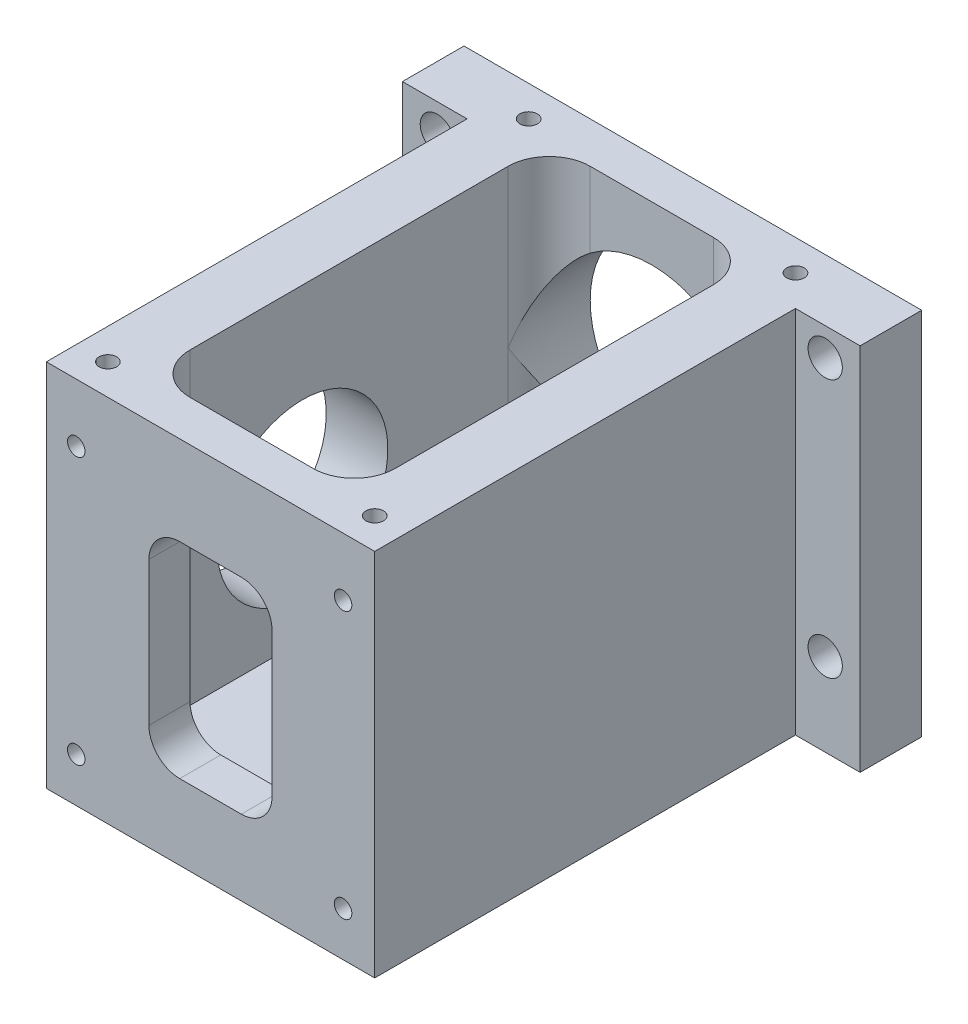
from build123d import *

# Parameters (mm, degrees)
SKETCH1_W                  = 50.8
SKETCH1_H                  = 74.6125
BOSS_EXTRUDE1_DEPTH        = 57.15
SKETCH2_W                  = 31.75
SKETCH2_H                  = 61.9125
CUT_EXTRUDE1_DEPTH         = 47.625
FILLET1_R                  = 6.35
CUT_EXTRUDE2_REACH         = 76.612
SKETCH3_R                  = 15.875
F_6_32_TAPPED_HOLE1_D      = 2.7051
F_6_32_TAPPED_HOLE1_DEPTH  = 7.62
F_6_32_TAPPED_HOLE1_TIP    = 0.81269403
SKETCH8_W                  = 9.525
SKETCH8_H                  = 57.15
BOSS_EXTRUDE2_DEPTH        = 10
M5_CLEARANCE_HOLE1_D       = 5.3
M5_CLEARANCE_HOLE1_DEPTH   = 9.525
CUT_EXTRUDE3_REACH         = 62.8
SKETCH11_R                 = 13.208
F_10_32_TAPPED_HOLE2_D     = 4.0386
F_10_32_TAPPED_HOLE2_DEPTH = 4.826
F_10_32_TAPPED_HOLE2_TIP   = 1.213317848
F_2_56_TAPPED_HOLE1_D      = 1.778
F_2_56_TAPPED_HOLE1_DEPTH  = 6.604
F_2_56_TAPPED_HOLE1_TIP    = 0.53416509
F_6_32_TAPPED_HOLE2_D      = 2.7051
F_6_32_TAPPED_HOLE2_DEPTH  = 9.0424
F_6_32_TAPPED_HOLE2_TIP    = 0.81269403
CUT_EXTRUDE6_REACH         = 76.613


with BuildPart() as part:
    # Sketch1 → Boss-Extrude1 (new body)
    with BuildSketch(Plane(origin=(0, 0, 0), x_dir=(1, 0, 0), z_dir=(0, 1, 0))):
        Rectangle(SKETCH1_W, SKETCH1_H)
    extrude(amount=BOSS_EXTRUDE1_DEPTH)

    # Sketch2 → Cut-Extrude1 (cut)
    with BuildSketch(Plane(origin=(0, 57.15, 0), x_dir=(1, 0, 0), z_dir=(0, 1, 0))):
        Rectangle(SKETCH2_W, SKETCH2_H)
    extrude(amount=-CUT_EXTRUDE1_DEPTH, mode=Mode.SUBTRACT)

    # Fillet1
    fillet1_edges = [part.edges().sort_by_distance(p)[0] for p in [
        (-15.875, 33.3375, -30.95625),
        (-15.875, 33.3375, 30.95625),
        (15.875, 33.3375, 30.95625),
        (15.875, 33.3375, -30.95625),
    ]]
    fillet(fillet1_edges, radius=FILLET1_R)

    # Sketch3 → Cut-Extrude2 (cut, up to next)
    with BuildSketch(Plane(origin=(0, 0, -37.30625), x_dir=(-1, 0, 0), z_dir=(0, 0, -1)), mode=Mode.PRIVATE) as cut_extrude2_sk1:
        with Locations((0, 32.825)):
            Circle(SKETCH3_R)
    cut_extrude2_tool1 = extrude(cut_extrude2_sk1.sketch, amount=-CUT_EXTRUDE2_REACH, mode=Mode.PRIVATE) & part.part
    add(cut_extrude2_tool1.solids().sort_by_distance((0, 32.825, -37.30625))[0], mode=Mode.SUBTRACT)

    # #6-32 Tapped Hole1
    with Locations(Plane(origin=(0, 57.15, 0), x_dir=(-1, 0, 0), z_dir=(0, 1, 0))):
        with Locations((20.6375, -32.54375), (-20.6375, -32.54375), (20.6375, 32.54375), (-20.6375, 32.54375)):
            Hole(F_6_32_TAPPED_HOLE1_D / 2, depth=F_6_32_TAPPED_HOLE1_DEPTH)
            with Locations((0, 0, -(F_6_32_TAPPED_HOLE1_DEPTH + F_6_32_TAPPED_HOLE1_TIP / 2))):  # 118° drill point
                Cone(0, F_6_32_TAPPED_HOLE1_D / 2, F_6_32_TAPPED_HOLE1_TIP, mode=Mode.SUBTRACT)

    # Sketch8 → Boss-Extrude2 (add)
    with BuildSketch(Plane.ZY.offset(25.4)):
        with Locations((-32.54375, 28.575)):
            Rectangle(SKETCH8_W, SKETCH8_H)
    boss_extrude2 = extrude(amount=BOSS_EXTRUDE2_DEPTH)

    # Mirror1: Boss-Extrude2 across plane
    add(boss_extrude2.mirror(Plane(origin=(0, 0, 0), x_dir=(0, 0, 1), z_dir=(1, 0, 0))))

    # M5 Clearance Hole1
    with Locations(Plane(origin=(0, 0, -37.30625), x_dir=(-1, 0, 0), z_dir=(0, 0, -1))):
        with Locations((30, 12.827), (30, 52.827), (-30, 52.827), (-30, 12.827)):
            Hole(M5_CLEARANCE_HOLE1_D / 2, depth=M5_CLEARANCE_HOLE1_DEPTH)

    # Sketch11 → Cut-Extrude3 (cut, up to next)
    with BuildSketch(Plane.ZY.offset(25.4), mode=Mode.PRIVATE) as cut_extrude3_sk1:
        with Locations((7.20725, 28.575)):
            Circle(SKETCH11_R)
    cut_extrude3_tool1 = extrude(cut_extrude3_sk1.sketch, amount=-CUT_EXTRUDE3_REACH, mode=Mode.PRIVATE) & part.part
    add(cut_extrude3_tool1.solids().sort_by_distance((-25.4, 28.575, 7.20725))[0], mode=Mode.SUBTRACT)

    # #10-32 Tapped Hole2
    with Locations(Plane.ZY.offset(25.4)):
        with Locations((-16.79575, 28.575), (-4.79425, 49.362207767), (19.20875, 49.362207767), (31.21025, 28.575), (19.20875, 7.787792233), (-4.79425, 7.787792233)):
            Hole(F_10_32_TAPPED_HOLE2_D / 2, depth=F_10_32_TAPPED_HOLE2_DEPTH)
            with Locations((0, 0, -(F_10_32_TAPPED_HOLE2_DEPTH + F_10_32_TAPPED_HOLE2_TIP / 2))):  # 118° drill point
                Cone(0, F_10_32_TAPPED_HOLE2_D / 2, F_10_32_TAPPED_HOLE2_TIP, mode=Mode.SUBTRACT)

    # #2-56 Tapped Hole1
    with Locations(Plane(origin=(0, 9.525, 0), x_dir=(-1, 0, 0), z_dir=(0, 1, 0))):
        with Locations((13, -12.163354521), (13, -25.163354521), (-13, -25.163354521), (-13, -12.163354521), (5.6515, 4.74375), (-5.6515, 4.74375)):
            Hole(F_2_56_TAPPED_HOLE1_D / 2, depth=F_2_56_TAPPED_HOLE1_DEPTH)
            with Locations((0, 0, -(F_2_56_TAPPED_HOLE1_DEPTH + F_2_56_TAPPED_HOLE1_TIP / 2))):  # 118° drill point
                Cone(0, F_2_56_TAPPED_HOLE1_D / 2, F_2_56_TAPPED_HOLE1_TIP, mode=Mode.SUBTRACT)

    # #6-32 Tapped Hole2
    with Locations(Plane.XY.offset(37.30625)):
        with Locations((20.50625, 48.141034847), (20.50625, 6.866034847), (-20.76875, 48.141034847), (-20.76875, 6.866034847)):
            Hole(F_6_32_TAPPED_HOLE2_D / 2, depth=F_6_32_TAPPED_HOLE2_DEPTH)
            with Locations((0, 0, -(F_6_32_TAPPED_HOLE2_DEPTH + F_6_32_TAPPED_HOLE2_TIP / 2))):  # 118° drill point
                Cone(0, F_6_32_TAPPED_HOLE2_D / 2, F_6_32_TAPPED_HOLE2_TIP, mode=Mode.SUBTRACT)

    # Sketch24 → Cut-Extrude6 (cut, up to next)
    with BuildSketch(Plane.XY.offset(37.30625), mode=Mode.PRIVATE) as cut_extrude6_sk1:
        with BuildLine():
            Line((-4.7625, 11.628534847), (4.7625, 11.628534847))
            ThreePointArc((4.7625, 11.628534847), (8.130096045, 13.023438801), (9.525, 16.391034847))
            Line((9.525, 16.391034847), (9.525, 38.616034847))
            ThreePointArc((9.525, 38.616034847), (8.130096045, 41.983630892), (4.7625, 43.378534847))
            Line((4.7625, 43.378534847), (-4.7625, 43.378534847))
            ThreePointArc((-4.7625, 43.378534847), (-8.130096045, 41.983630892), (-9.525, 38.616034847))
            Line((-9.525, 38.616034847), (-9.525, 16.391034847))
            ThreePointArc((-9.525, 16.391034847), (-8.130096045, 13.023438801), (-4.7625, 11.628534847))
        make_face()
    cut_extrude6_tool1 = extrude(cut_extrude6_sk1.sketch, amount=-CUT_EXTRUDE6_REACH, mode=Mode.PRIVATE) & part.part
    add(cut_extrude6_tool1.solids().sort_by_distance((0, 27.503535, 37.30625))[0], mode=Mode.SUBTRACT)


solid = part.part
